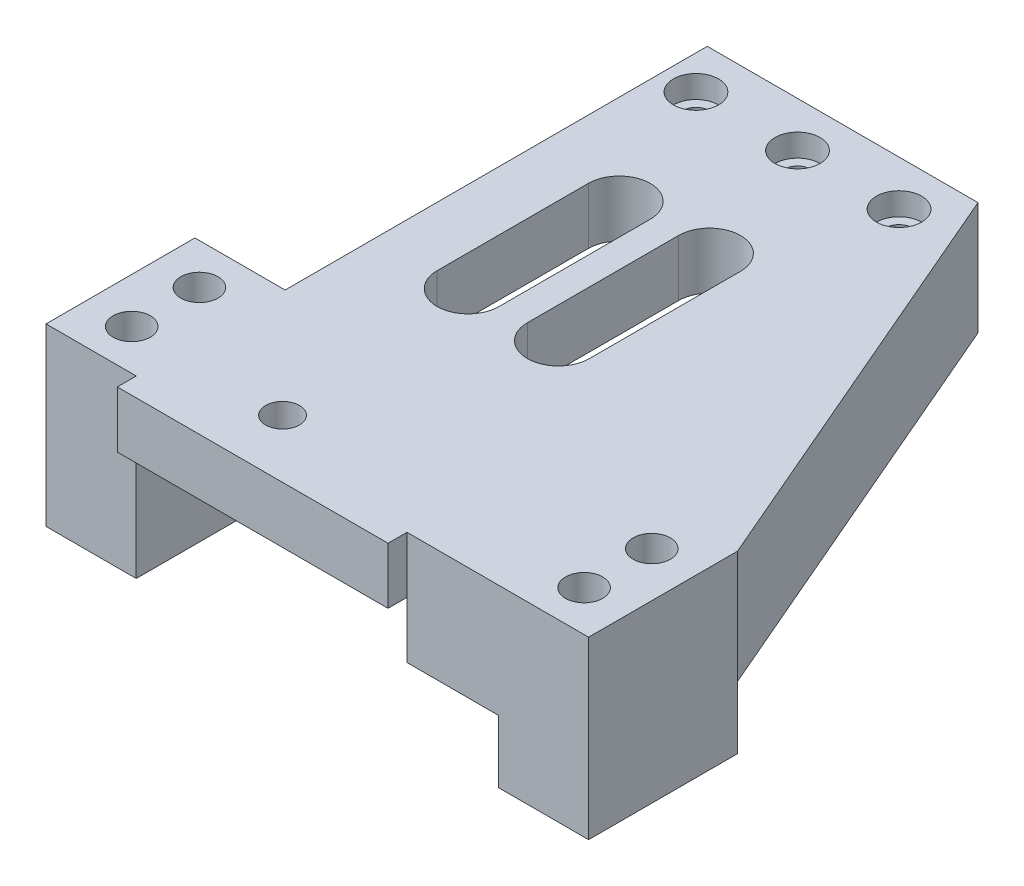
from build123d import *

# Parameters (mm, degrees)
BOSS_EXTRUDE1_DEPTH = 8
SKETCH2_R           = 1.15
CUT_EXTRUDE1_DEPTH  = 9
SKETCH3_R           = 2
CUT_EXTRUDE2_DEPTH  = 2
SKETCH5_W           = 24
SKETCH5_H           = 44.3
SKETCH5_R           = 1.5
BOSS_EXTRUDE2_DEPTH = 5
CUT_EXTRUDE3_DEPTH  = 20
SKETCH7_W           = 8
SKETCH7_H           = 13.2
SKETCH7_R           = 1.65
SKETCH7_W_2         = 16.1
BOSS_EXTRUDE3_DEPTH = 15.55
SKETCH8_W           = 8.1
SKETCH8_H           = 5.55
CUT_EXTRUDE4_DEPTH  = 25
BOSS_EXTRUDE4_DEPTH = 10


with BuildPart() as part:
    # Sketch1 → Boss-Extrude1 (new body)
    with BuildSketch(Plane.XY):
        Polygon((0, 0), (5.866666667, 0), (5.866666667, 3), (9.066666667, 3), (9.066666667, 0), (14.933333333, 0), (14.933333333, 3), (18.133333333, 3), (18.133333333, 0), (24, 0), (24, 8), (0, 8), align=None)
    extrude(amount=-BOSS_EXTRUDE1_DEPTH)

    # Sketch2 → Cut-Extrude1 (cut, through all)
    with BuildSketch(Plane(origin=(0, 8, 0), x_dir=(1, 0, 0), z_dir=(0, 1, 0))):
        with Locations((3, 4)):
            Circle(SKETCH2_R)
        with Locations((12, 4)):
            Circle(SKETCH2_R)
        with Locations((21, 4)):
            Circle(SKETCH2_R)
    extrude(amount=-CUT_EXTRUDE1_DEPTH, mode=Mode.SUBTRACT)

    # Sketch3 → Cut-Extrude2 (cut)
    with BuildSketch(Plane(origin=(0, 8, 0), x_dir=(1, 0, 0), z_dir=(0, 1, 0))):
        with Locations((3, 4)):
            Circle(SKETCH3_R)
        with Locations((12, 4)):
            Circle(SKETCH3_R)
        with Locations((21, 4)):
            Circle(SKETCH3_R)
    extrude(amount=-CUT_EXTRUDE2_DEPTH, mode=Mode.SUBTRACT)

    # Sketch5 → Boss-Extrude2 (add)
    with BuildSketch(Plane(origin=(0, 8, 0), x_dir=(1, 0, 0), z_dir=(0, 1, 0))):
        with Locations((12, -22.15)):
            Rectangle(SKETCH5_W, SKETCH5_H)
        with Locations((9.5, -39.149393889)):
            Circle(SKETCH5_R, mode=Mode.SUBTRACT)
    extrude(amount=-BOSS_EXTRUDE2_DEPTH)

    # Sketch6 → Cut-Extrude3 (cut)
    with BuildSketch(Plane(origin=(0, 8, 0), x_dir=(1, 0, 0), z_dir=(0, 1, 0))):
        with BuildLine():
            Line((10.75, -7.8), (10.75, -21.2))
            ThreePointArc((10.75, -21.2), (8, -23.95), (5.25, -21.2))
            Line((5.25, -21.2), (5.25, -7.8))
            ThreePointArc((5.25, -7.8), (8, -5.05), (10.75, -7.8))
        make_face()
        with BuildLine():
            Line((18.75, -7.8), (18.75, -21.2))
            ThreePointArc((18.75, -21.2), (16, -23.95), (13.25, -21.2))
            Line((13.25, -21.2), (13.25, -7.8))
            ThreePointArc((13.25, -7.8), (16, -5.05), (18.75, -7.8))
        make_face()
    extrude(amount=-CUT_EXTRUDE3_DEPTH, mode=Mode.SUBTRACT)

    # Sketch7 → Boss-Extrude3 (add)
    with BuildSketch(Plane(origin=(0, 8, 0), x_dir=(1, 0, 0), z_dir=(0, 1, 0))):
        with Locations((-4, -36.02)):
            Rectangle(SKETCH7_W, SKETCH7_H)
        with Locations((-4, -33.02)):
            Circle(SKETCH7_R, mode=Mode.SUBTRACT)
        with Locations((-4, -39.02)):
            Circle(SKETCH7_R, mode=Mode.SUBTRACT)
        with Locations((32.05, -36.02)):
            Rectangle(SKETCH7_W_2, SKETCH7_H)
        with Locations((36.1, -33.02)):
            Circle(SKETCH7_R, mode=Mode.SUBTRACT)
        with Locations((36.1, -39.02)):
            Circle(SKETCH7_R, mode=Mode.SUBTRACT)
    extrude(amount=-BOSS_EXTRUDE3_DEPTH)

    # Sketch8 → Cut-Extrude4 (cut)
    with BuildSketch(Plane.XY.offset(42.62)):
        with Locations((28.05, -4.775)):
            Rectangle(SKETCH8_W, SKETCH8_H)
    extrude(amount=-CUT_EXTRUDE4_DEPTH, mode=Mode.SUBTRACT)

    # Sketch10 → Boss-Extrude4 (add)
    with BuildSketch(Plane(origin=(0, 8, 0), x_dir=(1, 0, 0), z_dir=(0, 1, 0))):
        Polygon((40.1, -29.42), (24, 8), (24, -29.42), align=None)
    extrude(amount=-BOSS_EXTRUDE4_DEPTH)


solid = part.part
